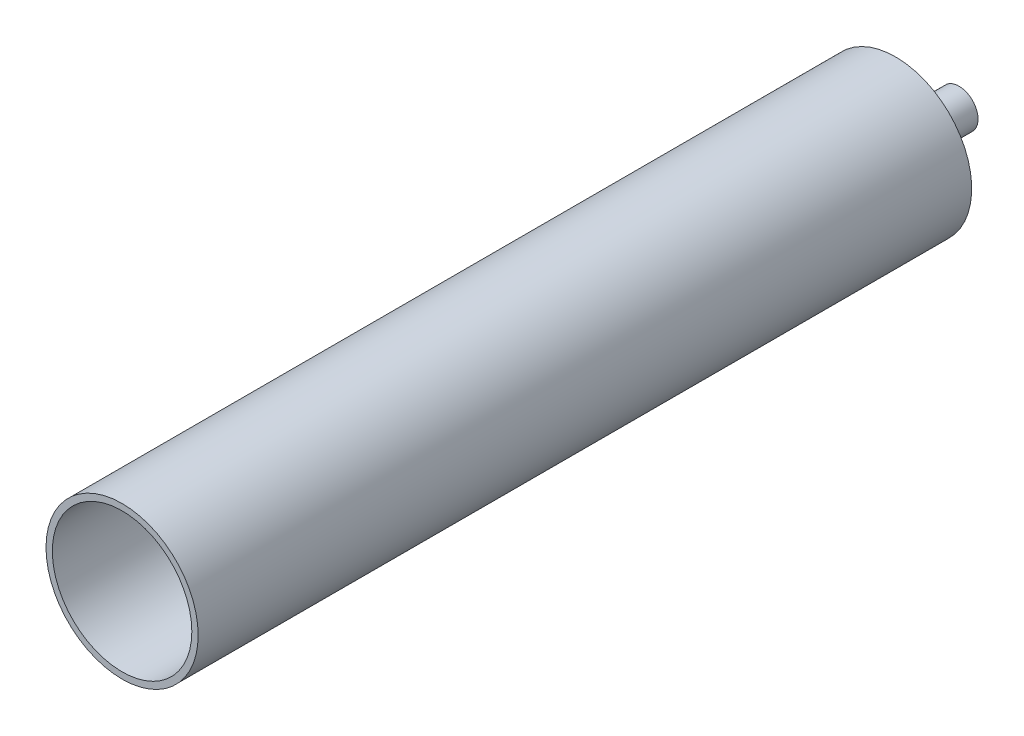
from build123d import *

# Parameters (mm, degrees)
SKETCH1_R           = 7.62
SKETCH1_R_2         = 6.985
BOSS_EXTRUDE1_DEPTH = 76.2
SKETCH2_R           = 7.62
BOSS_EXTRUDE2_DEPTH = 1.27
SKETCH3_R           = 1.905
SKETCH3_R_2         = 1.27
BOSS_EXTRUDE3_DEPTH = 6.35
SKETCH4_R           = 1.27
CUT_EXTRUDE1_DEPTH  = 1.27


with BuildPart() as part:
    # Sketch1 → Boss-Extrude1 (new body)
    with BuildSketch(Plane.XY):
        Circle(SKETCH1_R)
        Circle(SKETCH1_R_2, mode=Mode.SUBTRACT)
    extrude(amount=BOSS_EXTRUDE1_DEPTH)

    # Sketch2 → Boss-Extrude2 (add)
    with BuildSketch(Plane(origin=(0, 0, 0), x_dir=(-1, 0, 0), z_dir=(0, 0, -1))):
        Circle(SKETCH2_R)
    extrude(amount=BOSS_EXTRUDE2_DEPTH)

    # Sketch3 → Boss-Extrude3 (add)
    with BuildSketch(Plane(origin=(0, 0, -1.27), x_dir=(-1, 0, 0), z_dir=(0, 0, -1))):
        Circle(SKETCH3_R)
        Circle(SKETCH3_R_2, mode=Mode.SUBTRACT)
    extrude(amount=BOSS_EXTRUDE3_DEPTH)

    # Sketch4 → Cut-Extrude1 (cut)
    with BuildSketch(Plane(origin=(0, 0, -1.27), x_dir=(-1, 0, 0), z_dir=(0, 0, -1))):
        Circle(SKETCH4_R)
    extrude(amount=-CUT_EXTRUDE1_DEPTH, mode=Mode.SUBTRACT)


solid = part.part
